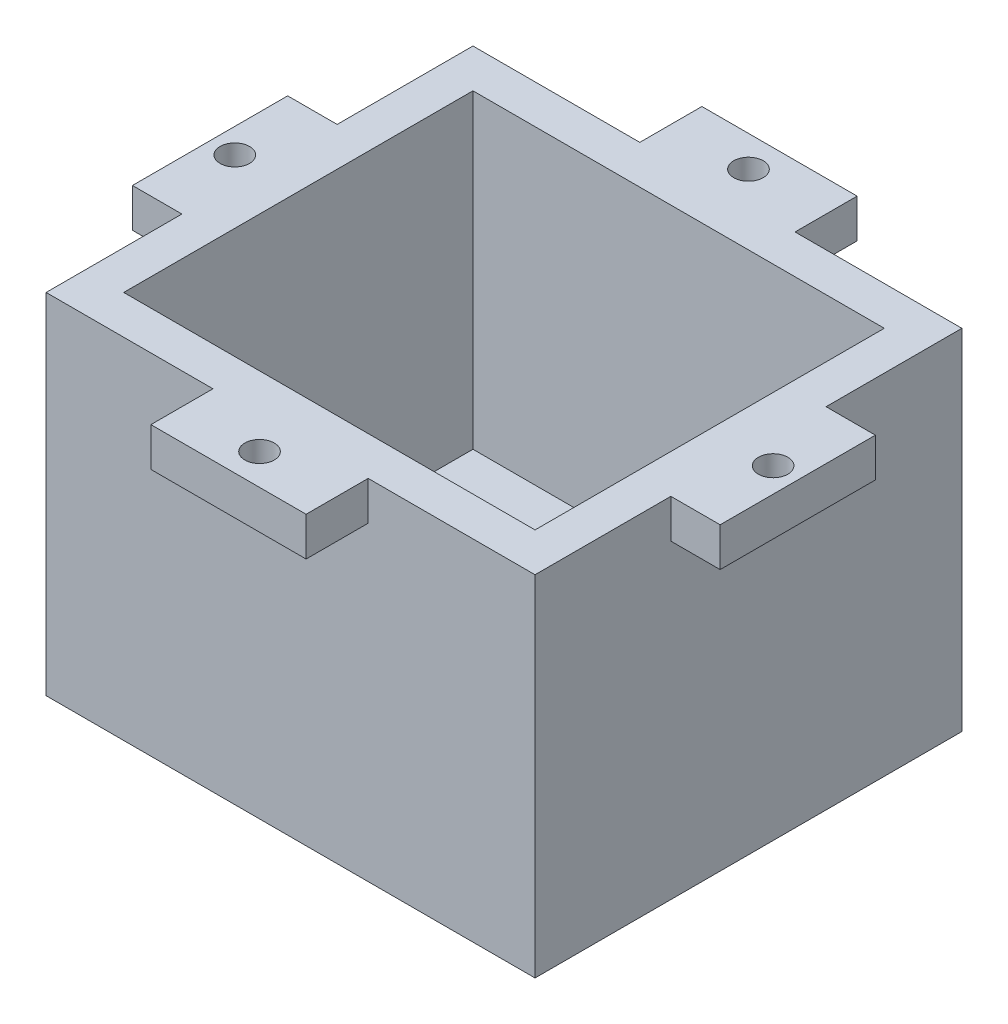
from build123d import *

# Parameters (mm, degrees)
SKETCH1_W             = 63
SKETCH1_H             = 55
BOSS_EXTRUDE1_DEPTH   = 45
SHELL1_T              = -5
SKETCH5_W             = 20
SKETCH5_H             = 8
SKETCH5_W_2           = 6.3754
SKETCH5_H_2           = 20
SKETCH5_W_3           = 6.35
BOSS_EXTRUDE3_DEPTH   = 5
F_6_CLEARANCE_HOLE1_D = 3.7973


with BuildPart() as part:
    # Sketch1 → Boss-Extrude1 (new body)
    with BuildSketch(Plane(origin=(0, 0, 0), x_dir=(1, 0, 0), z_dir=(0, 1, 0))):
        with Locations((-11.452841564, -4.099064972)):
            Rectangle(SKETCH1_W, SKETCH1_H)
    extrude(amount=BOSS_EXTRUDE1_DEPTH)

    # Shell1
    shell1_openings = [part.faces().sort_by_distance(p)[0] for p in [
        (-11.452841564, 45, 4.099064972),
    ]]
    offset(amount=SHELL1_T, openings=shell1_openings, kind=Kind.INTERSECTION)

    # Sketch5 → Boss-Extrude3 (add)
    with BuildSketch(Plane(origin=(0, 45, 0), x_dir=(1, 0, 0), z_dir=(0, 1, 0))):
        with Locations((-11.452841564, 27.400935028)):
            Rectangle(SKETCH5_W, SKETCH5_H)
        with Locations((-11.452841564, -35.599064972)):
            Rectangle(SKETCH5_W, SKETCH5_H)
        with Locations((-46.140541564, -4.099064972)):
            Rectangle(SKETCH5_W_2, SKETCH5_H_2)
        with Locations((23.222158436, -4.099064972)):
            Rectangle(SKETCH5_W_3, SKETCH5_H_2)
    extrude(amount=-BOSS_EXTRUDE3_DEPTH)

    # #6 Clearance Hole1 (through all)
    with Locations(Plane(origin=(0, 40, 0), x_dir=(-1, 0, 0), z_dir=(0, -1, 0))):
        with Locations((11.452841564, -35.599064972), (11.452841564, 27.400935028), (46.140541564, -4.099064972), (-23.222158436, -4.099064972)):
            Hole(F_6_CLEARANCE_HOLE1_D / 2)


solid = part.part
